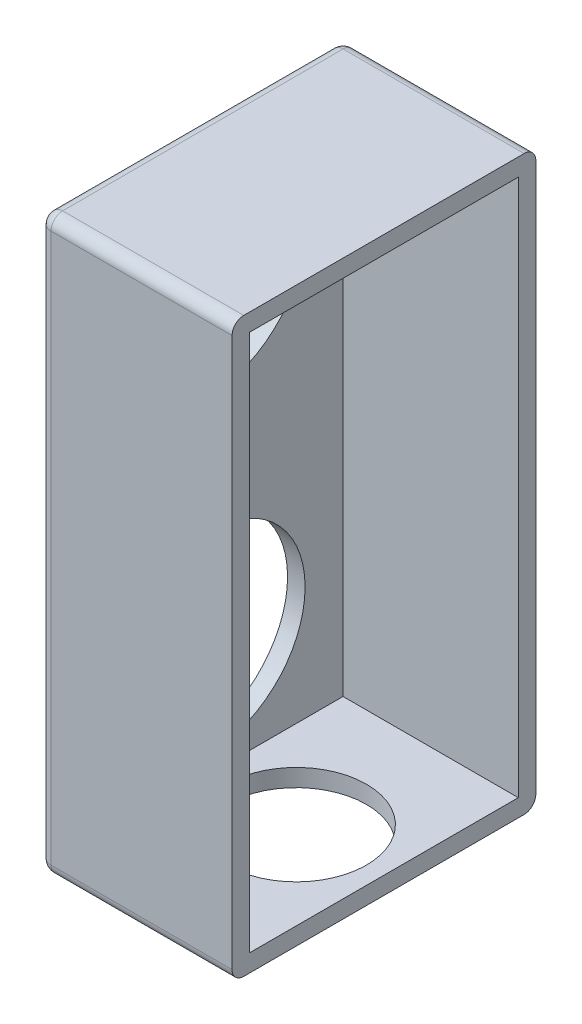
from build123d import *

# Parameters (mm, degrees)
SKETCH_1_W          = 15
SKETCH_1_H          = 23
EXTRUDE_1_DEPTH     = 46
SHELL_1_T           = 1.5
SKETCH_2_R          = 6
CUT_EXTRUDE_4_DEPTH = 1.5
SKETCH_3_R          = 8.25
CUT_EXTRUDE_5_DEPTH = 1.5
FILLET_2_R          = 1


with BuildPart() as part:
    # 草图1 → 凸台-拉伸1 (new body)
    with BuildSketch(Plane(origin=(0, 0, 0), x_dir=(1, 0, 0), z_dir=(0, 1, 0))):
        Rectangle(SKETCH_1_W, SKETCH_1_H)
    extrude(amount=EXTRUDE_1_DEPTH)

    # 抽壳1
    shell_1_openings = [part.faces().sort_by_distance(p)[0] for p in [
        (7.5, 23, 0),
    ]]
    offset(amount=SHELL_1_T, openings=shell_1_openings, kind=Kind.INTERSECTION)

    # 草图2 → 切除-拉伸4 (cut)
    with BuildSketch(Plane(origin=(0, 0, 0), x_dir=(-1, 0, 0), z_dir=(0, -1, 0))):
        with Locations(Location((0, 0, 0), (0, 0, 90))):
            Circle(SKETCH_2_R)
    extrude(amount=CUT_EXTRUDE_4_DEPTH, mode=Mode.SUBTRACT)

    # 草图3 → 切除-拉伸5 (cut)
    with BuildSketch(Plane.ZY.offset(9)):
        with Locations((0, 36.25)):
            Circle(SKETCH_3_R)
        with Locations(Location((0, 9.75, 0), (0, 0, 180))):
            Circle(SKETCH_3_R)
    extrude(amount=-CUT_EXTRUDE_5_DEPTH, mode=Mode.SUBTRACT)

    # 圆角2
    fillet_2_edges = [part.edges().sort_by_distance(p)[0] for p in [
        (-0.75, 47.5, -13),
        (-9, 47.5, 0),
        (-0.75, -1.5, -13),
        (-0.75, -1.5, 13),
        (-9, -1.5, 0),
        (-9, 23, -13),
        (-9, 23, 13),
        (-0.75, 47.5, 13),
    ]]
    fillet(fillet_2_edges, radius=FILLET_2_R)


solid = part.part
